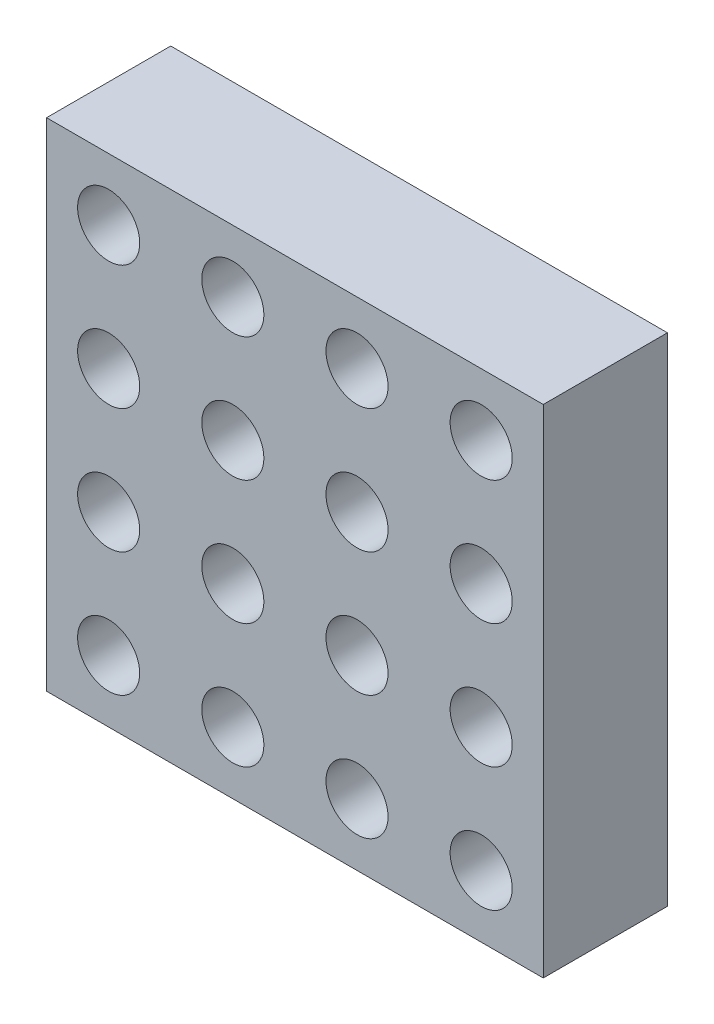
from build123d import *

# Parameters (mm, degrees)
SKETCH1_W            = 40
SKETCH1_H            = 40
BOSS_EXTRUDE1_DEPTH  = 10
SKETCH3_R            = 2.5
CUT_EXTRUDE1_DEPTH   = 11
LPATTERN1_COUNT      = 4
LPATTERN1_PITCH      = 10
LPATTERN1_COUNT_DIR2 = 4
LPATTERN1_PITCH_DIR2 = 10


with BuildPart() as part:
    # Sketch1 → Boss-Extrude1 (new body)
    with BuildSketch(Plane.XY):
        Rectangle(SKETCH1_W, SKETCH1_H)
    extrude(amount=BOSS_EXTRUDE1_DEPTH)

    # Sketch3 → Cut-Extrude1 (cut, through all)
    with BuildSketch(Plane.XY.offset(10)):
        with Locations((15, 15)):
            Circle(SKETCH3_R)
    cut_extrude1 = extrude(amount=-CUT_EXTRUDE1_DEPTH, mode=Mode.SUBTRACT)

    # LPattern1: Cut-Extrude1 4 × 4
    with Locations(*[(-i * LPATTERN1_PITCH, -j * LPATTERN1_PITCH_DIR2, 0) for i in range(LPATTERN1_COUNT) for j in range(LPATTERN1_COUNT_DIR2) if (i, j) != (0, 0)]):
        add(cut_extrude1, mode=Mode.SUBTRACT)


solid = part.part
